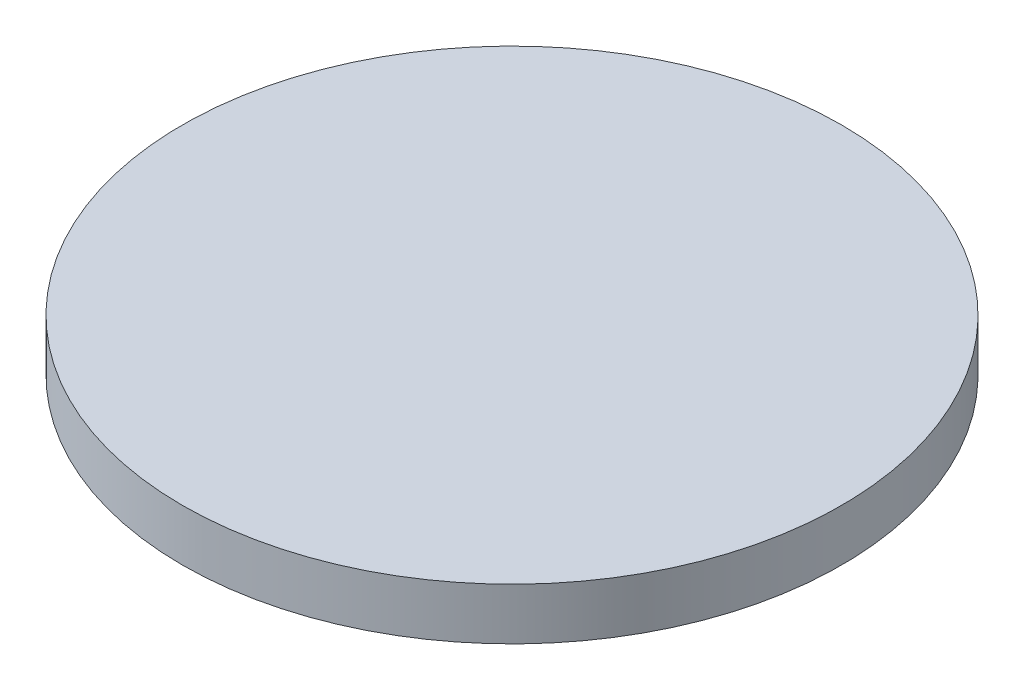
from build123d import *

# Parameters (mm, degrees)
SKETCH2_R           = 63.75
BOSS_EXTRUDE1_DEPTH = 5


with BuildPart() as part:
    # Sketch2 → Boss-Extrude1 (new body, symmetric)
    with BuildSketch(Plane(origin=(0, 0, 0), x_dir=(1, 0, 0), z_dir=(0, 1, 0))):
        Circle(SKETCH2_R)
    extrude(amount=BOSS_EXTRUDE1_DEPTH, both=True)


solid = part.part
